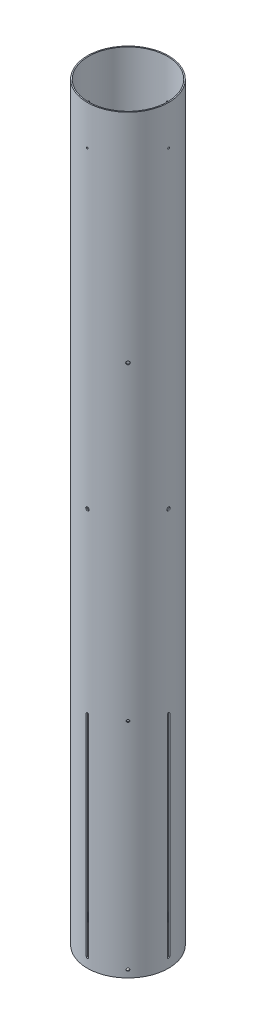
from build123d import *

# Parameters (mm, degrees)
SUSTAINER_TUBE_PROFILE_R       = 78.359
SUSTAINER_TUBE_PROFILE_R_2     = 76.2
SUSTAINER_TUBE_BODY_DEPTH      = 1447.8
FIN_SLOT_PROFILE_W             = 2.38125
FIN_SLOT_PROFILE_H             = 406.4
FIN_SLOT_CUT_DEPTH             = 2.196216
FIN_SLOT_PATTERN_COUNT         = 4
SKETCH2_R                      = 3.175
VENT_HOLE_DEPTH                = 111.816360687
CUT_EXTRUDE3_START             = -79.359000102
SKETCH3_R                      = 3.2639
CUT_EXTRUDE3_DEPTH             = 158.718000218
CIRPATTERN2_COUNT              = 4
CUT_EXTRUDE4_REACH             = 191.175
SKETCH4_R                      = 2.57937
CUT_EXTRUDE4_DIRECTION_2_DEPTH = 33.457360687
CIRPATTERN3_COUNT              = 4


with BuildPart() as part:
    # Sustainer Tube Profile → Sustainer Tube Body (new body)
    with BuildSketch(Plane(origin=(0, 0, 0), x_dir=(1, 0, 0), z_dir=(0, 1, 0))):
        Circle(SUSTAINER_TUBE_PROFILE_R)
        Circle(SUSTAINER_TUBE_PROFILE_R_2, mode=Mode.SUBTRACT)
    extrude(amount=SUSTAINER_TUBE_BODY_DEPTH)

    # Fin Slot Profile → Fin Slot Cut (cut)
    with BuildSketch(Plane.XY.offset(78.359)):
        with BuildLine():
            ThreePointArc((-2.38125, 19.05), (0, 16.66875), (2.38125, 19.05))
            Line((2.38125, 19.05), (0, 19.05))
            Line((0, 19.05), (-2.38125, 19.05))
        make_face()
        with Locations((1.190625, 222.25)):
            Rectangle(FIN_SLOT_PROFILE_W, FIN_SLOT_PROFILE_H)
        with Locations((-1.190625, 222.25)):
            Rectangle(FIN_SLOT_PROFILE_W, FIN_SLOT_PROFILE_H)
        with BuildLine():
            Line((0, 425.45), (2.38125, 425.45))
            ThreePointArc((2.38125, 425.45), (0, 427.83125), (-2.38125, 425.45))
            Line((-2.38125, 425.45), (0, 425.45))
        make_face()
    fin_slot_cut = extrude(amount=-FIN_SLOT_CUT_DEPTH, mode=Mode.SUBTRACT)

    # Fin Slot Pattern: Fin Slot Cut ×4 about axis
    fin_slot_pattern_axis = Axis((0, 0, 0), (0, 1, 0))
    for i in range(1, FIN_SLOT_PATTERN_COUNT):
        add(fin_slot_cut.rotate(fin_slot_pattern_axis, i * 360 / FIN_SLOT_PATTERN_COUNT), mode=Mode.SUBTRACT)

    # Sketch2 → Vent Hole (cut, through all)
    with BuildSketch(Plane(origin=(0, 0, 0), x_dir=(0.707106781, 0, -0.707106781), z_dir=(0.707106781, 0, 0.707106781))):
        with Locations((0, 1028.7)):
            Circle(SKETCH2_R)
    extrude(amount=VENT_HOLE_DEPTH, mode=Mode.SUBTRACT)

    # Sketch3 → Cut-Extrude3 (cut)
    with BuildSketch(Plane.XY.offset(CUT_EXTRUDE3_START)):
        with Locations((0, 768.35)):
            Circle(SKETCH3_R)
    cut_extrude3 = extrude(amount=CUT_EXTRUDE3_DEPTH, mode=Mode.SUBTRACT)

    # CirPattern2: Cut-Extrude3 ×4 about axis
    cirpattern2_axis = Axis((0, 1447.8, 0), (0, 1, 0))
    for i in range(1, CIRPATTERN2_COUNT):
        add(cut_extrude3.rotate(cirpattern2_axis, i * 360 / CIRPATTERN2_COUNT), mode=Mode.SUBTRACT)

    # Sketch4 → Cut-Extrude4 (cut, up to next)
    with BuildSketch(Plane(origin=(55.408180267, 0, 55.408180267), x_dir=(0, -1, 0), z_dir=(0.707106781, 0, 0.707106781)), mode=Mode.PRIVATE) as cut_extrude4_sk1:
        with Locations((-14.0462, 0)):
            Circle(SKETCH4_R)
    cut_extrude4_tool1 = extrude(cut_extrude4_sk1.sketch, amount=-CUT_EXTRUDE4_REACH, mode=Mode.PRIVATE) & part.part
    add(cut_extrude4_tool1.solids().sort_by_distance((55.40818, 14.0462, 55.40818))[0], mode=Mode.SUBTRACT)
    # Sketch4 → Cut-Extrude4 (cut, up to next)
    with BuildSketch(Plane(origin=(55.408180267, 0, 55.408180267), x_dir=(0, -1, 0), z_dir=(0.707106781, 0, 0.707106781)), mode=Mode.PRIVATE) as cut_extrude4_sk2:
        with Locations((-429.925500066, 0)):
            Circle(SKETCH4_R)
    cut_extrude4_tool2 = extrude(cut_extrude4_sk2.sketch, amount=-CUT_EXTRUDE4_REACH, mode=Mode.PRIVATE) & part.part
    add(cut_extrude4_tool2.solids().sort_by_distance((55.40818, 429.9255, 55.40818))[0], mode=Mode.SUBTRACT)

    # Sketch4 → Cut-Extrude4 direction 2 (cut)
    with BuildSketch(Plane(origin=(55.408180267, 0, 55.408180267), x_dir=(0, -1, 0), z_dir=(0.707106781, 0, 0.707106781))):
        with Locations((-14.0462, 0)):
            Circle(SKETCH4_R)
        with Locations((-429.925500066, 0)):
            Circle(SKETCH4_R)
    extrude(amount=CUT_EXTRUDE4_DIRECTION_2_DEPTH, mode=Mode.SUBTRACT)

    # Sketch10 → #4 Clearance Hole1 (revolve, cut)
    with BuildSketch(Plane(origin=(-78.359, 1371.6, 0), x_dir=(0, 0, 1), z_dir=(0, 1, 0))):
        Polygon((0, 0), (0, 5.806574487), (1.63195, 4.826), (1.63195, 0), align=None)
    f_4_clearance_hole1 = revolve(axis=Axis((-84.709, 1371.6, 0), (1, 0, 0)), mode=Mode.SUBTRACT)

    # CirPattern3: #4 Clearance Hole1 ×4 about axis
    cirpattern3_axis = Axis((0, 1447.8, 0), (0, 1, 0))
    for i in range(1, CIRPATTERN3_COUNT):
        add(f_4_clearance_hole1.rotate(cirpattern3_axis, i * 360 / CIRPATTERN3_COUNT), mode=Mode.SUBTRACT)


solid = part.part
